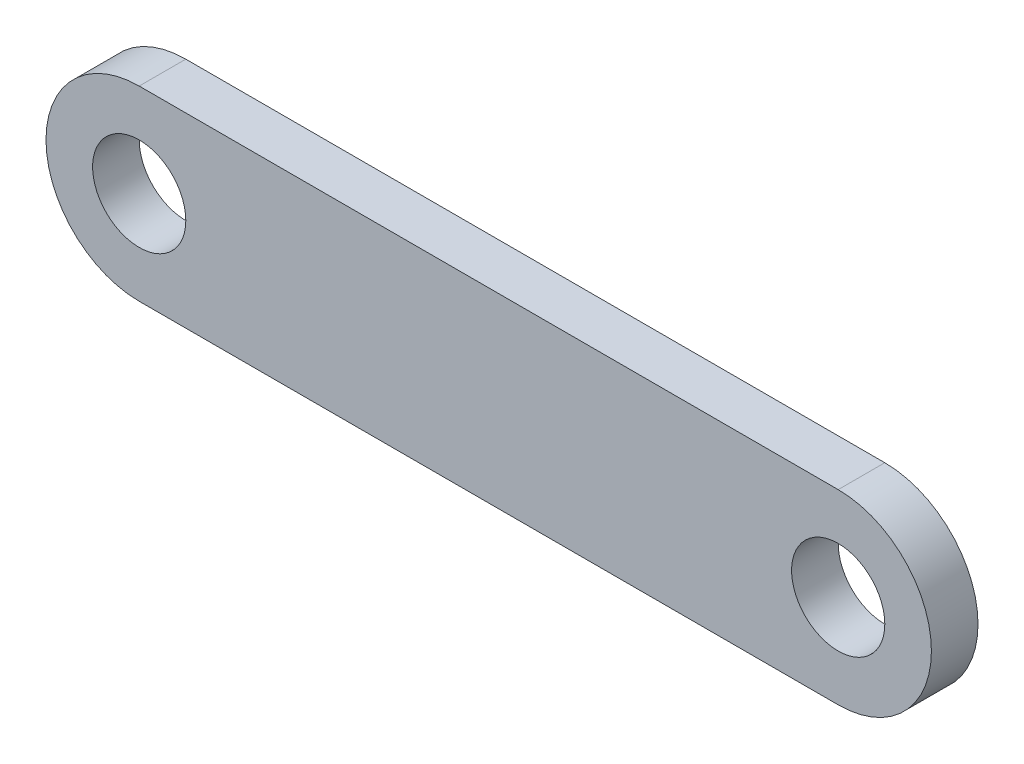
from build123d import *

# Parameters (mm, degrees)
SKETCH1_R           = 2.54
BOSS_EXTRUDE1_DEPTH = 2.54


with BuildPart() as part:
    # Sketch1 → Boss-Extrude1 (new body)
    with BuildSketch(Plane.XY):
        with BuildLine():
            Line((0, 5.08), (38.1, 5.08))
            ThreePointArc((38.1, 5.08), (43.18, 0), (38.1, -5.08))
            Line((38.1, -5.08), (0, -5.08))
            ThreePointArc((0, -5.08), (-5.08, 0), (0, 5.08))
        make_face()
        Circle(SKETCH1_R, mode=Mode.SUBTRACT)
        with Locations((38.1, 0)):
            Circle(SKETCH1_R, mode=Mode.SUBTRACT)
    extrude(amount=BOSS_EXTRUDE1_DEPTH)


solid = part.part
